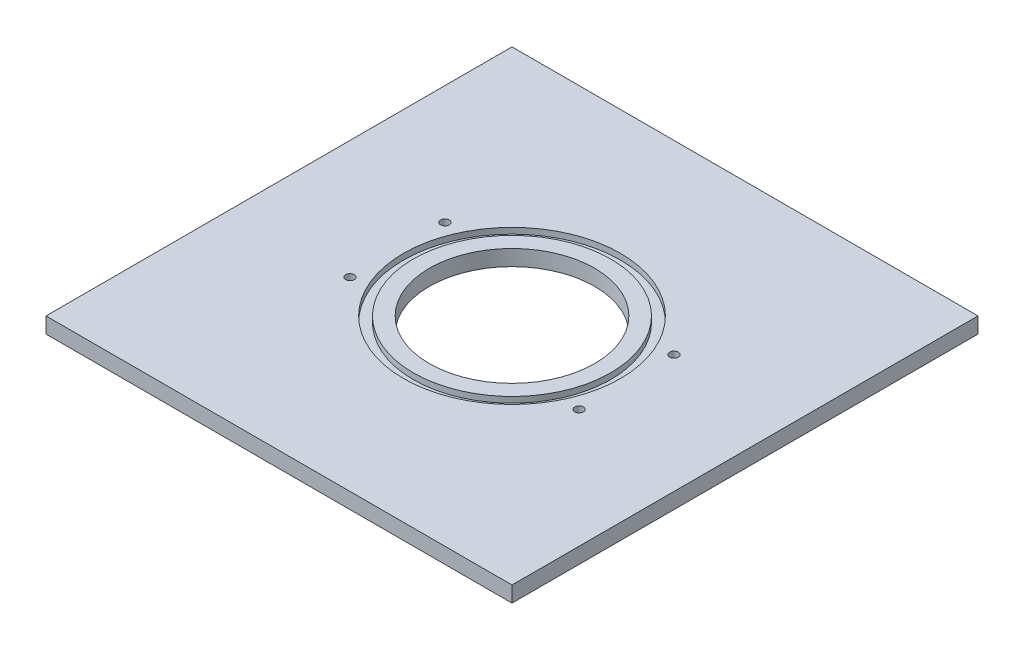
from build123d import *

# Parameters (mm, degrees)
SKETCH1_W           = 225.552
SKETCH1_H           = 225.552
SKETCH1_R           = 52.5
SKETCH1_R_2         = 60
SKETCH1_R_3         = 47.7502
SKETCH1_R_4         = 40
BOSS_EXTRUDE1_DEPTH = 7.62
CUT_EXTRUDE1_START  = 7.62
SKETCH1_4_R         = 52.5
SKETCH1_4_R_2       = 47.7502
CUT_EXTRUDE1_DEPTH  = 2.8448
CIRPATTERN1_COUNT   = 16


with BuildPart() as part:
    # Sketch1 → Boss-Extrude1 (new body)
    with BuildSketch(Plane(origin=(0, 0, 0), x_dir=(1, 0, 0), z_dir=(0, 1, 0))):
        Rectangle(SKETCH1_W, SKETCH1_H)
        Circle(SKETCH1_R, mode=Mode.SUBTRACT)
        Circle(SKETCH1_R_2)
        Circle(SKETCH1_R, mode=Mode.SUBTRACT)
        Circle(SKETCH1_R)
        Circle(SKETCH1_R_3, mode=Mode.SUBTRACT)
        Circle(SKETCH1_R_3)
        with Locations(Location((0, 0, 0), (0, 0, 90))):
            Circle(SKETCH1_R_4, mode=Mode.SUBTRACT)
    extrude(amount=BOSS_EXTRUDE1_DEPTH)

    # Sketch1_4 → Cut-Extrude1 (cut)
    with BuildSketch(Plane(origin=(0, 0, 0), x_dir=(1, 0, 0), z_dir=(0, 1, 0)).offset(CUT_EXTRUDE1_START)):
        with Locations(Location((0, 0, 0), (0, 0, 270))):
            Circle(SKETCH1_4_R)
        with Locations(Location((0, 0, 0), (0, 0, 270))):
            Circle(SKETCH1_4_R_2, mode=Mode.SUBTRACT)
    extrude(amount=-CUT_EXTRUDE1_DEPTH, mode=Mode.SUBTRACT)

    # Sketch4 → M5x0.8 Tapped Hole2 (revolve, cut)
    with BuildSketch(Plane(origin=(55.432771951, 7.62, -22.961005942), x_dir=(0, 0, 1), z_dir=(1, 0, 0))):
        Polygon((0, 0), (0, 13.6618073), (2.1, 12.4), (2.1, 0), align=None)
    m5x0_8_tapped_hole2 = revolve(axis=Axis((55.432771951, 13.97, -22.961005942), (0, -1, 0)), mode=Mode.SUBTRACT)

    # CirPattern1: M5x0.8 Tapped Hole2 ×16 about axis, 12 skipped
    cirpattern1_axis = Axis((0, 7.62, 0), (0, 1, 0))
    add([m5x0_8_tapped_hole2.rotate(cirpattern1_axis, i * 360 / CIRPATTERN1_COUNT) for i in range(1, CIRPATTERN1_COUNT) if i not in (1, 2, 3, 4, 5, 7, 9, 10, 11, 12, 13, 15)], mode=Mode.SUBTRACT)


solid = part.part
